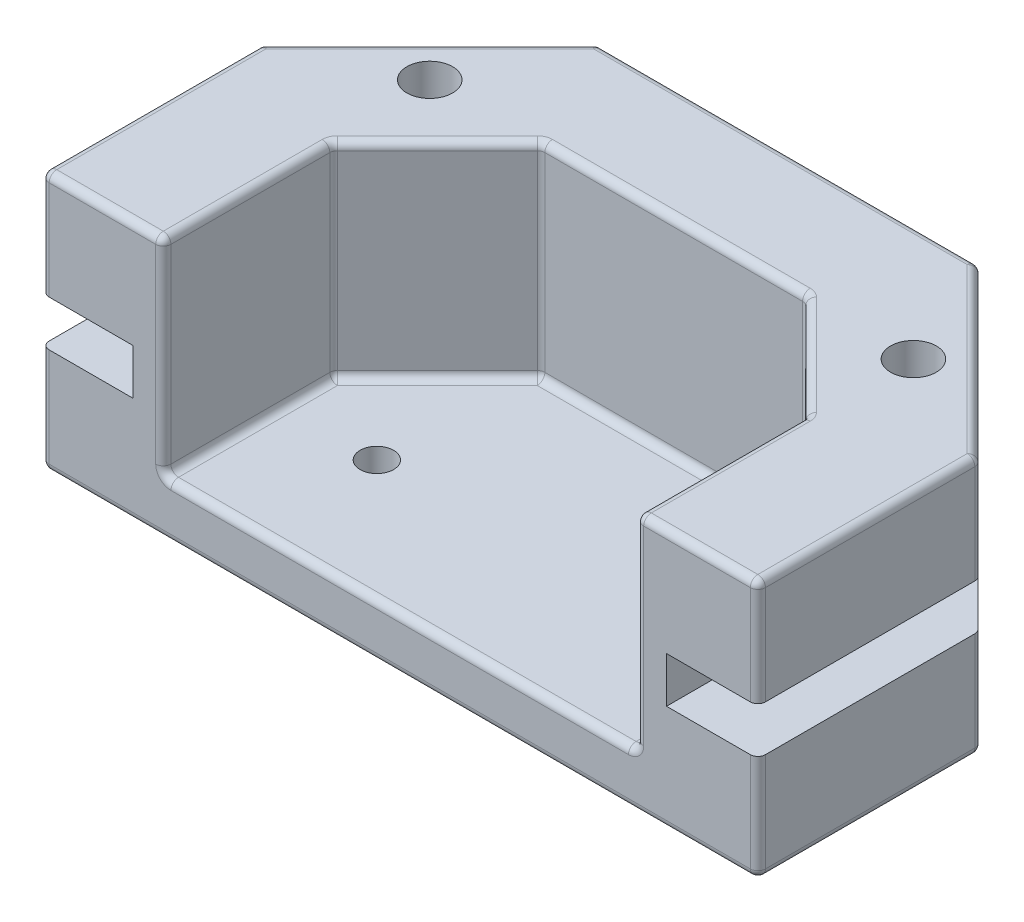
from build123d import *

# Parameters (mm, degrees)
BOSS_EXTRUDE1_DEPTH      = 10
BOSS_EXTRUDE1_DEPTH_BACK = 7
BOSS_EXTRUDE4_START      = -7
BOSS_EXTRUDE4_DEPTH      = 3.5
FILLET1_R                = 0.5
CUT_EXTRUDE1_DEPTH       = 3
SKETCH2_R                = 1.5
CUT_EXTRUDE2_DEPTH       = 17
CUT_EXTRUDE3_START       = -3.5
SKETCH4_R                = 1.1
CUT_EXTRUDE3_DEPTH       = 3.5


with BuildPart() as part:
    # Sketch1 → Boss-Extrude1 (new body, two sides)
    with BuildSketch(Plane(origin=(0, 0, 0), x_dir=(1, 0, 0), z_dir=(0, 1, 0))) as boss_extrude1_sk:
        Polygon((21.473368866, -52.5), (29.473368866, -52.5), (29.473368866, -41.355058259), (36.328427125, -34.5), (53.671572875, -34.5), (60.526631134, -41.355058259), (60.526631134, -52.5), (68.526631134, -52.5), (68.526631134, -38.04134976), (57.485281374, -27), (32.514718626, -27), (21.473368866, -38.04134976), align=None)
    extrude(amount=BOSS_EXTRUDE1_DEPTH)
    extrude(boss_extrude1_sk.sketch, amount=-BOSS_EXTRUDE1_DEPTH_BACK)

    # Sketch1_5 → Boss-Extrude4 (add)
    with BuildSketch(Plane(origin=(0, 0, 0), x_dir=(1, 0, 0), z_dir=(0, 1, 0)).offset(BOSS_EXTRUDE4_START)):
        Polygon((60.526631134, -41.355058259), (60.526631134, -52.5), (29.473368866, -52.5), (29.473368866, -41.355058259), (36.328427125, -34.5), (53.671572875, -34.5), align=None)
    extrude(amount=BOSS_EXTRUDE4_DEPTH)

    # Fillet1
    fillet1_edges = [part.edges().sort_by_distance(p)[0] for p in [
        (45, -7, 52.5),
        (68.526631134, -7, 45.27067488),
        (63.005956254, -7, 32.52067488),
        (21.473368866, 1.5, 52.5),
        (21.473368866, 1.5, 38.04134976),
        (32.514718626, 1.5, 27),
        (57.485281374, 1.5, 27),
        (68.526631134, 1.5, 38.04134976),
        (68.526631134, 1.5, 52.5),
        (45, -7, 27),
        (26.994043746, -7, 32.52067488),
        (68.526631134, 10, 45.27067488),
        (63.005956254, 10, 32.52067488),
        (45, 10, 27),
        (26.994043746, 10, 32.52067488),
        (21.473368866, 10, 45.27067488),
        (25.473368866, 10, 52.5),
        (21.473368866, -7, 45.27067488),
        (60.526631134, 10, 46.927529129),
        (64.526631134, 10, 52.5),
        (29.473368866, 10, 46.927529129),
        (32.900897995, 10, 37.927529129),
        (45, 10, 34.5),
        (57.099102005, 10, 37.927529129),
        (60.526631134, 3.25, 52.5),
        (29.473368866, 3.25, 52.5),
        (29.473368866, 3.25, 41.355058259),
        (36.328427125, 3.25, 34.5),
        (53.671572875, 3.25, 34.5),
        (60.526631134, 3.25, 41.355058259),
        (45, -3.5, 52.5),
        (32.900897995, -3.5, 37.927529129),
        (29.473368866, -3.5, 46.927529129),
        (60.526631134, -3.5, 46.927529129),
        (57.099102005, -3.5, 37.927529129),
        (45, -3.5, 34.5),
    ]]
    fillet(fillet1_edges, radius=FILLET1_R)

    # Sketch1_3 → Cut-Extrude1 (cut)
    with BuildSketch(Plane(origin=(0, 0, 0), x_dir=(1, 0, 0), z_dir=(0, 1, 0))):
        Polygon((21.473368866, -52.5), (27.473368866, -52.5), (27.473368866, -40.526631134), (35, -33), (55, -33), (62.526631134, -40.526631134), (62.526631134, -52.5), (68.526631134, -52.5), (68.526631134, -38.04134976), (57.485281374, -27), (32.514718626, -27), (21.473368866, -38.04134976), align=None)
    extrude(amount=CUT_EXTRUDE1_DEPTH, mode=Mode.SUBTRACT)

    # Sketch2 → Cut-Extrude2 (cut)
    with BuildSketch(Plane(origin=(0, 10, 0), x_dir=(1, 0, 0), z_dir=(0, 1, 0))):
        with Locations((29.11536409, -34.641995223)):
            Circle(SKETCH2_R)
        with Locations((60.88463591, -34.641995223)):
            Circle(SKETCH2_R)
    extrude(amount=-CUT_EXTRUDE2_DEPTH, mode=Mode.SUBTRACT)

    # Sketch4 → Cut-Extrude3 (cut)
    with BuildSketch(Plane(origin=(0, 0, 0), x_dir=(1, 0, 0), z_dir=(0, 1, 0)).offset(CUT_EXTRUDE3_START)):
        with Locations((35.5, -44.5)):
            Circle(SKETCH4_R)
        with Locations((54.5, -44.5)):
            Circle(SKETCH4_R)
    extrude(amount=-CUT_EXTRUDE3_DEPTH, mode=Mode.SUBTRACT)


solid = part.part
